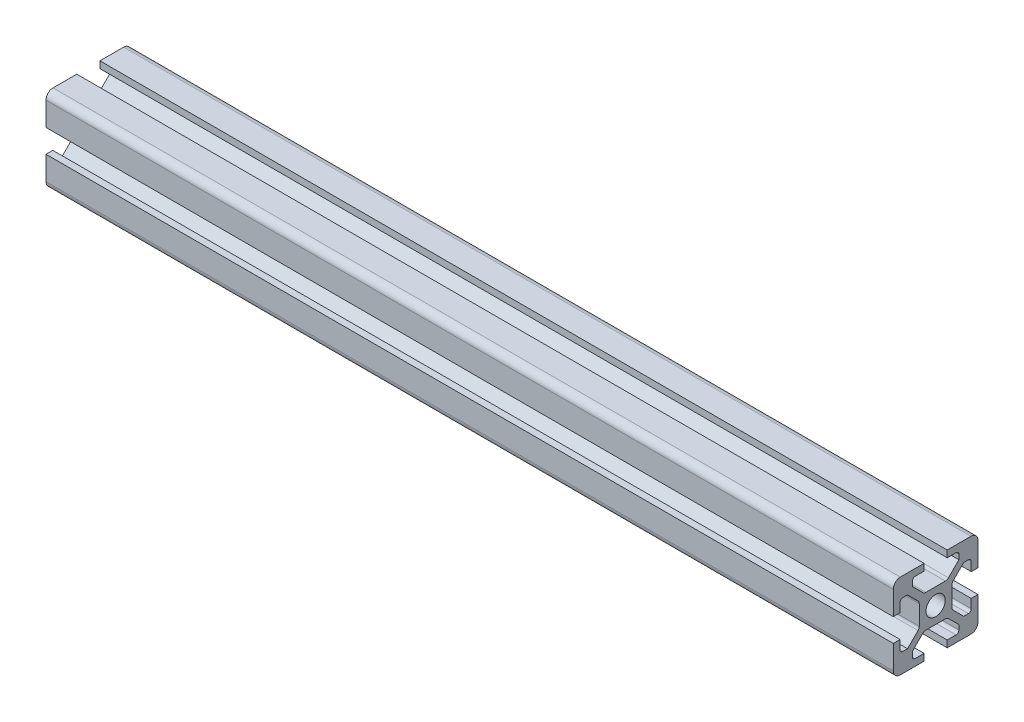
from build123d import *

# Parameters (mm, degrees)
SKETCH1_R           = 3.4
BOSS_EXTRUDE2_DEPTH = 100
FILLET5_R           = 2.5
FILLET6_R           = 1.5
FILLET7_R           = 1.5
FILLET8_R           = 1
SKETCH3_R           = 3.4
BOSS_EXTRUDE4_DEPTH = 200


with BuildPart() as part:
    # Sketch1 → Boss-Extrude2 (new body)
    with BuildSketch(Plane(origin=(0, 0, 0), x_dir=(0, 0, -1), z_dir=(1, 0, 0))):
        Polygon((10.9, 0), (10.9, 2.4), (6.75, 2.4), (6.75, 5.05), (10.9, 9.2), (19.1, 9.2), (23.25, 5.05), (23.25, 2.4), (19.1, 2.4), (19.1, 0), (30, 0), (30, 10.9), (27.6, 10.9), (27.6, 6.75), (24.95, 6.75), (20.8, 10.9), (20.8, 19.1), (24.95, 23.25), (27.6, 23.25), (27.6, 19.1), (30, 19.1), (30, 30), (19.1, 30), (19.1, 27.6), (23.25, 27.6), (23.25, 24.95), (19.1, 20.8), (10.9, 20.8), (6.75, 24.95), (6.75, 27.6), (10.9, 27.6), (10.9, 30), (0, 30), (0, 19.1), (2.4, 19.1), (2.4, 23.25), (5.05, 23.25), (9.2, 19.1), (9.2, 10.9), (5.05, 6.75), (2.4, 6.75), (2.4, 10.9), (0, 10.9), (0, 0), align=None)
        with Locations((15, 15)):
            Circle(SKETCH1_R, mode=Mode.SUBTRACT)
    extrude(amount=BOSS_EXTRUDE2_DEPTH)

    # Fillet5
    fillet5_edges = [part.edges().sort_by_distance(p)[0] for p in [
        (50, 30, 0),
        (50, 30, -30),
        (50, 0, -30),
        (50, 0, 0),
    ]]
    fillet(fillet5_edges, radius=FILLET5_R)

    # Fillet6
    fillet6_edges = [part.edges().sort_by_distance(p)[0] for p in [
        (50, 10.9, -9.2),
        (50, 19.1, -9.2),
        (50, 19.1, -20.8),
        (50, 10.9, -20.8),
        (50, 9.2, -19.1),
        (50, 9.2, -10.9),
    ]]
    fillet(fillet6_edges, radius=FILLET6_R)

    # Fillet7
    fillet7_edges = [part.edges().sort_by_distance(p)[0] for p in [
        (50, 20.8, -10.9),
        (50, 20.8, -19.1),
    ]]
    fillet(fillet7_edges, radius=FILLET7_R)

    # Fillet8
    fillet8_edges = [part.edges().sort_by_distance(p)[0] for p in [
        (50, 6.75, -2.4),
        (50, 23.25, -2.4),
        (50, 27.6, -6.75),
        (50, 27.6, -23.25),
        (50, 23.25, -27.6),
        (50, 6.75, -27.6),
        (50, 2.4, -23.25),
        (50, 2.4, -6.75),
    ]]
    fillet(fillet8_edges, radius=FILLET8_R)

    # Sketch3 → Boss-Extrude4 (add)
    with BuildSketch(Plane(origin=(0, 0, 0), x_dir=(0, 0, -1), z_dir=(1, 0, 0))):
        with BuildLine():
            Line((10.9, 27.6), (10.9, 30))
            Line((10.9, 30), (2.5, 30))
            ThreePointArc((2.5, 30), (0.732233047, 29.267766953), (0, 27.5))
            Line((0, 27.5), (0, 19.1))
            Line((0, 19.1), (2.4, 19.1))
            Line((2.4, 19.1), (2.4, 22.25))
            ThreePointArc((2.4, 22.25), (2.692893219, 22.957106781), (3.4, 23.25))
            Line((3.4, 23.25), (5.05, 23.25))
            Line((5.05, 23.25), (8.760660172, 19.539339828))
            ThreePointArc((8.760660172, 19.539339828), (9.085819299, 19.052704805), (9.2, 18.478679656))
            Line((9.2, 18.478679656), (9.2, 11.521320344))
            ThreePointArc((9.2, 11.521320344), (9.085819299, 10.947295195), (8.760660172, 10.460660172))
            Line((8.760660172, 10.460660172), (5.05, 6.75))
            Line((5.05, 6.75), (3.4, 6.75))
            ThreePointArc((3.4, 6.75), (2.692893219, 7.042893219), (2.4, 7.75))
            Line((2.4, 7.75), (2.4, 10.9))
            Line((2.4, 10.9), (0, 10.9))
            Line((0, 10.9), (0, 2.5))
            ThreePointArc((0, 2.5), (0.732233047, 0.732233047), (2.5, 0))
            Line((2.5, 0), (10.9, 0))
            Line((10.9, 0), (10.9, 2.4))
            Line((10.9, 2.4), (7.75, 2.4))
            ThreePointArc((7.75, 2.4), (7.042893219, 2.692893219), (6.75, 3.4))
            Line((6.75, 3.4), (6.75, 5.05))
            Line((6.75, 5.05), (10.460660172, 8.760660172))
            ThreePointArc((10.460660172, 8.760660172), (10.947295195, 9.085819299), (11.521320344, 9.2))
            Line((11.521320344, 9.2), (18.478679656, 9.2))
            ThreePointArc((18.478679656, 9.2), (19.052704805, 9.085819299), (19.539339828, 8.760660172))
            Line((19.539339828, 8.760660172), (23.25, 5.05))
            Line((23.25, 5.05), (23.25, 3.4))
            ThreePointArc((23.25, 3.4), (22.957106781, 2.692893219), (22.25, 2.4))
            Line((22.25, 2.4), (19.1, 2.4))
            Line((19.1, 2.4), (19.1, 0))
            Line((19.1, 0), (27.5, 0))
            ThreePointArc((27.5, 0), (29.267766953, 0.732233047), (30, 2.5))
            Line((30, 2.5), (30, 10.9))
            Line((30, 10.9), (27.6, 10.9))
            Line((27.6, 10.9), (27.6, 7.75))
            ThreePointArc((27.6, 7.75), (27.307106781, 7.042893219), (26.6, 6.75))
            Line((26.6, 6.75), (24.95, 6.75))
            Line((24.95, 6.75), (21.239339828, 10.460660172))
            ThreePointArc((21.239339828, 10.460660172), (20.914180701, 10.947295195), (20.8, 11.521320344))
            Line((20.8, 11.521320344), (20.8, 18.478679656))
            ThreePointArc((20.8, 18.478679656), (20.914180701, 19.052704805), (21.239339828, 19.539339828))
            Line((21.239339828, 19.539339828), (24.95, 23.25))
            Line((24.95, 23.25), (26.6, 23.25))
            ThreePointArc((26.6, 23.25), (27.307106781, 22.957106781), (27.6, 22.25))
            Line((27.6, 22.25), (27.6, 19.1))
            Line((27.6, 19.1), (30, 19.1))
            Line((30, 19.1), (30, 27.5))
            ThreePointArc((30, 27.5), (29.267766953, 29.267766953), (27.5, 30))
            Line((27.5, 30), (19.1, 30))
            Line((19.1, 30), (19.1, 27.6))
            Line((19.1, 27.6), (22.25, 27.6))
            ThreePointArc((22.25, 27.6), (22.957106781, 27.307106781), (23.25, 26.6))
            Line((23.25, 26.6), (23.25, 24.95))
            Line((23.25, 24.95), (19.539339828, 21.239339828))
            ThreePointArc((19.539339828, 21.239339828), (19.052704805, 20.914180701), (18.478679656, 20.8))
            Line((18.478679656, 20.8), (11.521320344, 20.8))
            ThreePointArc((11.521320344, 20.8), (10.947295195, 20.914180701), (10.460660172, 21.239339828))
            Line((10.460660172, 21.239339828), (6.75, 24.95))
            Line((6.75, 24.95), (6.75, 26.6))
            ThreePointArc((6.75, 26.6), (7.042893219, 27.307106781), (7.75, 27.6))
            Line((7.75, 27.6), (10.9, 27.6))
        make_face()
        with Locations((15, 15)):
            Circle(SKETCH3_R, mode=Mode.SUBTRACT)
    extrude(amount=-BOSS_EXTRUDE4_DEPTH)


solid = part.part
